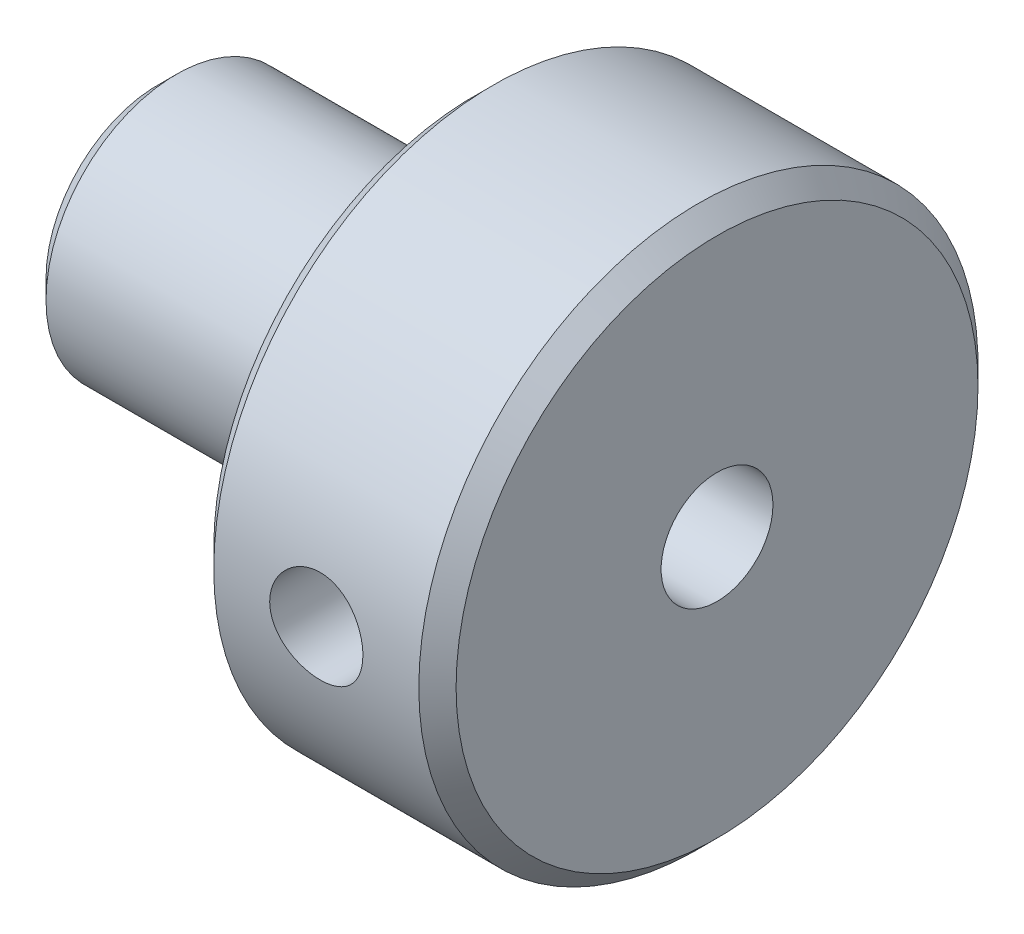
from build123d import *

# Parameters (mm, degrees)
M3_TAPPED_HOLE1_D            = 2.5
M3_TAPPED_HOLE1_DEPTH        = 8
M3_TAPPED_HOLE1_TIP          = 0.751075774
F_3_0_3_DIAMETER_HOLE1_D     = 3
F_3_0_3_DIAMETER_HOLE1_DEPTH = 3
F_3_0_3_DIAMETER_HOLE1_TIP   = 0.901290929
M3_TAPPED_HOLE2_D            = 2.5
M3_TAPPED_HOLE2_DEPTH        = 12
M3_TAPPED_HOLE2_TIP          = 0.751075774
CHAMFER1_SIZE                = 0.5


with BuildPart() as part:
    # Sketch1 → Revolve1 (revolve)
    with BuildSketch(Plane.XY):
        Polygon((0, 0), (0, 3.5), (8.5, 3.5), (8.5, 7.5), (15, 7.5), (15, 0), align=None)
    revolve(axis=Axis((0, 0, 0), (1, 0, 0)))

    # M3 Tapped Hole1
    with Locations(Plane.ZY):
        with Locations((0, 0)):
            Hole(M3_TAPPED_HOLE1_D / 2, depth=M3_TAPPED_HOLE1_DEPTH)
            with Locations((0, 0, -(M3_TAPPED_HOLE1_DEPTH + M3_TAPPED_HOLE1_TIP / 2))):  # 118° drill point
                Cone(0, M3_TAPPED_HOLE1_D / 2, M3_TAPPED_HOLE1_TIP, mode=Mode.SUBTRACT)

    # Ø3.0 (3) Diameter Hole1
    with Locations(Plane(origin=(15, 0, 0), x_dir=(0, 0, -1), z_dir=(1, 0, 0))):
        with Locations((0, 0)):
            Hole(F_3_0_3_DIAMETER_HOLE1_D / 2, depth=F_3_0_3_DIAMETER_HOLE1_DEPTH)
            with Locations((0, 0, -(F_3_0_3_DIAMETER_HOLE1_DEPTH + F_3_0_3_DIAMETER_HOLE1_TIP / 2))):  # 118° drill point
                Cone(0, F_3_0_3_DIAMETER_HOLE1_D / 2, F_3_0_3_DIAMETER_HOLE1_TIP, mode=Mode.SUBTRACT)

    # M3 Tapped Hole2
    with Locations(Plane.XY.offset(7.5)):
        with Locations((11.75, 0)):
            Hole(M3_TAPPED_HOLE2_D / 2, depth=M3_TAPPED_HOLE2_DEPTH)
            with Locations((0, 0, -(M3_TAPPED_HOLE2_DEPTH + M3_TAPPED_HOLE2_TIP / 2))):  # 118° drill point
                Cone(0, M3_TAPPED_HOLE2_D / 2, M3_TAPPED_HOLE2_TIP, mode=Mode.SUBTRACT)

    # Chamfer1
    chamfer1_edges = [part.edges().sort_by_distance(p)[0] for p in [
        (15, -7.5, 0),
        (8.5, -7.5, 0),
        (0, -3.5, 0),
    ]]
    chamfer(chamfer1_edges, length=CHAMFER1_SIZE)


solid = part.part
